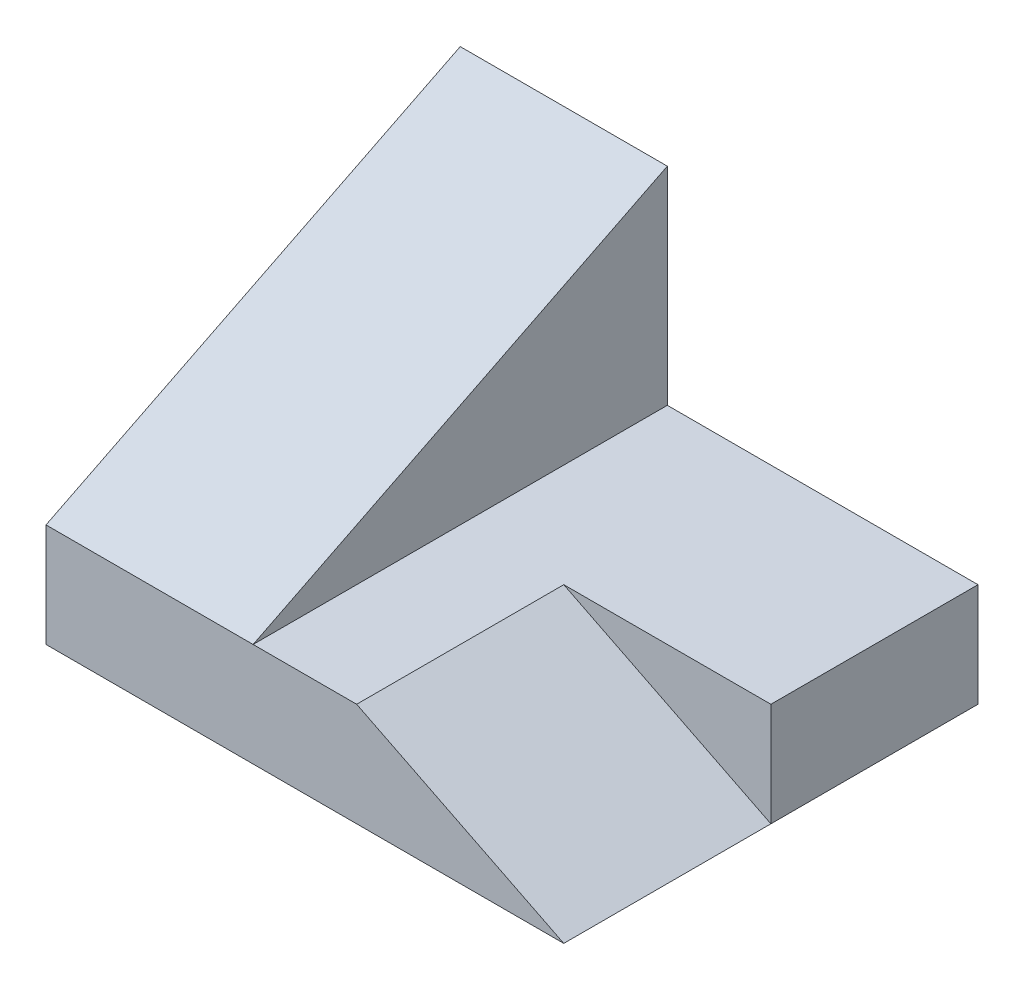
from build123d import *

# Parameters (mm, degrees)
BOSS_EXTRUDE1_DEPTH     = 101.6
CUT_EXTRUDE2_DEPTH      = 77.2
CUT_EXTRUDE2_DEPTH_BACK = 51.8
CUT_EXTRUDE6_DEPTH      = 50.8


with BuildPart() as part:
    # Sketch1 → Boss-Extrude1 (new body)
    with BuildSketch(Plane.XY):
        Polygon((-63.5, 76.2), (-12.7, 76.2), (-12.7, 25.4), (63.5, 25.4), (63.5, 0), (-63.5, 0), align=None)
    extrude(amount=BOSS_EXTRUDE1_DEPTH)

    # Sketch2 → Cut-Extrude2 (cut, two sides)
    with BuildSketch(Plane(origin=(-12.7, 0, 0), x_dir=(0, 0, -1), z_dir=(1, 0, 0))) as cut_extrude2_sk:
        Polygon((236.128778424, 194.264389212), (0, 76.2), (-101.6, 25.4), (-337.728778424, -92.664389212), (-573.857556848, 379.593167636), (0, 666.52194606), align=None)
    extrude(amount=CUT_EXTRUDE2_DEPTH, mode=Mode.SUBTRACT)
    extrude(cut_extrude2_sk.sketch, amount=-CUT_EXTRUDE2_DEPTH_BACK, mode=Mode.SUBTRACT)

    # Sketch3 → Cut-Extrude6 (cut)
    with BuildSketch(Plane.XY.offset(101.6)):
        Polygon((63.5, 25.4), (12.7, 25.4), (63.5, 0), align=None)
    extrude(amount=-CUT_EXTRUDE6_DEPTH, mode=Mode.SUBTRACT)


solid = part.part
